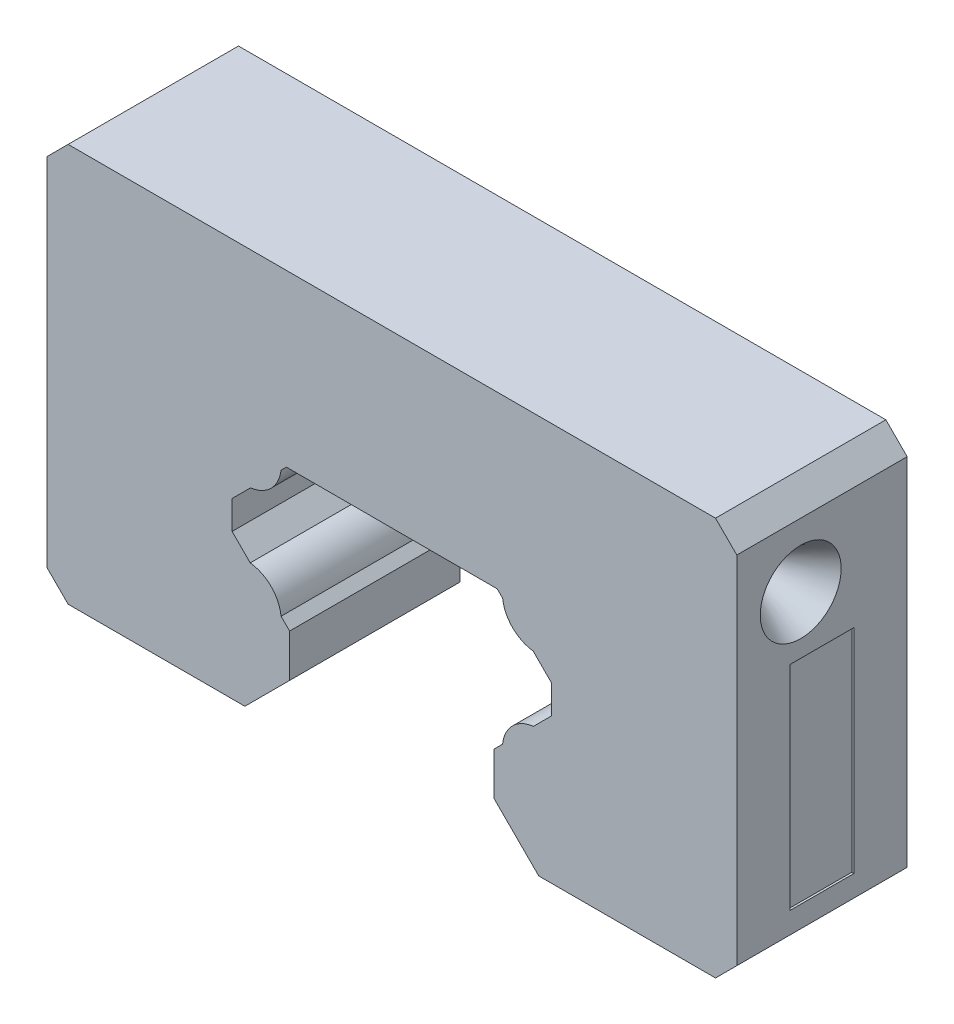
from build123d import *

# Parameters (mm, degrees)
EXTRUDE_1_DEPTH     = 8
SKETCH_1_R          = 1.9
CUT_EXTRUDE_1_DEPTH = 3
CUT_EXTRUDE_1_TAPER = 31
SKETCH_2_R          = 1.9
CUT_EXTRUDE_2_DEPTH = 3
CUT_EXTRUDE_2_TAPER = 31
SKETCH_3_W          = 3
SKETCH_3_H          = 10
CUT_EXTRUDE_5_DEPTH = 0.1
SKETCH_4_W          = 3
SKETCH_4_H          = 10
CUT_EXTRUDE_6_DEPTH = 0.1
EXTRUDE_2_DEPTH     = 0.1


with BuildPart() as part:
    # Model → Бобышка-Вытянуть1 (new body)
    with BuildSketch(Plane.XY):
        with BuildLine():
            Line((4.7998047, 2.0996344), (6.8994391, 0))
            Line((6.8994391, 0), (15.2, 0))
            Line((15.2, 0), (16.2, 1))
            Line((16.2, 1), (16.2, 17.7))
            Line((16.2, 17.7), (15.2, 18.7))
            Line((15.2, 18.7), (-15.2, 18.7))
            Line((-15.2, 18.7), (-16.2, 17.7))
            Line((-16.2, 17.7), (-16.2, 1))
            Line((-16.2, 1), (-15.2, 0))
            Line((-15.2, 0), (-6.8994391, 0))
            Line((-6.8994391, 0), (-4.7998047, 2.0996344))
            Line((-4.7998047, 2.0996344), (-4.7998047, 4.109149262))
            Line((-4.7998047, 4.109149262), (-5.20075838, 4.510103152))
            ThreePointArc((-5.20075838, 4.510103152), (-5.668922208, 5.489261508), (-6.648080611, 5.957425238))
            Line((-6.648080611, 5.957425238), (-7.5, 6.809345046))
            Line((-7.5, 6.809345046), (-7.5, 8.149454443))
            Line((-7.5, 8.149454443), (-6.634490912, 9.014965186))
            ThreePointArc((-6.634490912, 9.014965186), (-5.668922174, 9.481617126), (-5.202270193, 10.447185846))
            Line((-5.202270193, 10.447185846), (-4.949456226, 10.7))
            Line((-4.949456226, 10.7), (4.949456226, 10.7))
            Line((4.949456226, 10.7), (5.202270193, 10.447185846))
            ThreePointArc((5.202270193, 10.447185846), (5.668922174, 9.481617126), (6.634490912, 9.014965186))
            Line((6.634490912, 9.014965186), (7.5, 8.149454443))
            Line((7.5, 8.149454443), (7.5, 6.809345046))
            Line((7.5, 6.809345046), (6.648080611, 5.957425238))
            ThreePointArc((6.648080611, 5.957425238), (5.668922208, 5.489261508), (5.20075838, 4.510103152))
            Line((5.20075838, 4.510103152), (4.7998047, 4.109149262))
            Line((4.7998047, 4.109149262), (4.7998047, 2.0996344))
        make_face()
    extrude(amount=EXTRUDE_1_DEPTH)

    # Эскиз1 → Вырез-Вытянуть1 (cut)
    with BuildSketch(Plane.ZY.offset(16.2)):
        with Locations((5, 14.7)):
            Circle(SKETCH_1_R)
    extrude(amount=-CUT_EXTRUDE_1_DEPTH, taper=CUT_EXTRUDE_1_TAPER, mode=Mode.SUBTRACT)

    # Эскиз2 → Вырез-Вытянуть2 (cut)
    with BuildSketch(Plane(origin=(16.2, 0, 0), x_dir=(0, 0, -1), z_dir=(1, 0, 0))):
        with Locations((-5, 14.7)):
            Circle(SKETCH_2_R)
    extrude(amount=-CUT_EXTRUDE_2_DEPTH, taper=CUT_EXTRUDE_2_TAPER, mode=Mode.SUBTRACT)

    # Эскиз3 → Вырез-Вытянуть5 (cut)
    with BuildSketch(Plane.ZY.offset(16.2)):
        with Locations((4, 7)):
            Rectangle(SKETCH_3_W, SKETCH_3_H)
    extrude(amount=-CUT_EXTRUDE_5_DEPTH, mode=Mode.SUBTRACT)

    # Эскиз4 → Вырез-Вытянуть6 (cut)
    with BuildSketch(Plane(origin=(16.2, 0, 0), x_dir=(0, 0, -1), z_dir=(1, 0, 0))):
        with Locations((-4, 7)):
            Rectangle(SKETCH_4_W, SKETCH_4_H)
    extrude(amount=-CUT_EXTRUDE_6_DEPTH, mode=Mode.SUBTRACT)

    # Эскиз6 → Бобышка-Вытянуть2 (add)
    with BuildSketch(Plane.ZY.offset(16.1)):
        Polygon((3.03007211, 3.44508547), (3.03007211, 3.635042735), (3.898448178, 3.635042735), (3.898448178, 4.720512821), (3.03007211, 4.720512821), (3.03007211, 4.910470085), (5.146738777, 4.910470085), (5.146738777, 4.720512821), (4.115542195, 4.720512821), (4.115542195, 3.635042735), (5.146738777, 3.635042735), (5.146738777, 3.44508547), align=None)
        with BuildLine():
            Line((3.418466875, 7.407051282), (3.5456704, 7.240838675))
            add(Edge.make_bspline(
                [(3.5456704, 7.240838675), (3.531539739, 7.228981659), (3.503468928, 7.205427486), (3.464048076, 7.167535373), (3.427128407, 7.128036745), (3.392472706, 7.086986558), (3.361473859, 7.043434815), (3.331717649, 6.999040962), (3.305665063, 6.952191972), (3.27383857, 6.88773774), (3.241351764, 6.803091843), (3.213410305, 6.696904819), (3.195791064, 6.5859033), (3.193869837, 6.510191456), (3.192892623, 6.471681357)],
                knots=[0, 0, 0, 0, 5.5327e-05, 0.000109907, 0.000163905, 0.000217489, 0.000270921, 0.000324195, 0.000377734, 0.000431589, 0.000539781, 0.000649006, 0.000760546, 0.000876009, 0.000876009, 0.000876009, 0.000876009], degree=3))
            add(Edge.make_bspline(
                [(3.192892623, 6.471681357), (3.193136924, 6.450464314), (3.193623259, 6.408227142), (3.200039254, 6.345544494), (3.209056985, 6.284032315), (3.222437538, 6.223730619), (3.239354312, 6.164716163), (3.259568731, 6.106603141), (3.284578555, 6.050232912), (3.312221197, 5.994825728), (3.343443407, 5.941740068), (3.377499946, 5.891512036), (3.414007532, 5.844321884), (3.453110993, 5.800143045), (3.494604828, 5.758890728), (3.538953905, 5.721084035), (3.585684118, 5.686217839), (3.634834276, 5.654490849), (3.685946619, 5.62592919), (3.739312968, 5.601913277), (3.794019585, 5.58093794), (3.850454299, 5.564079212), (3.908242017, 5.550838897), (3.967622137, 5.541685152), (4.028482077, 5.535343514), (4.069732399, 5.534859408), (4.090525502, 5.534615385)],
                knots=[0, 0, 0, 0, 6.3624e-05, 0.000126658, 0.000188844, 0.000250057, 0.000311794, 0.000372946, 0.000434469, 0.000496666, 0.000558624, 0.000619072, 0.00067861, 0.000737485, 0.000795951, 0.000853991, 0.000912166, 0.000970736, 0.001029382, 0.001087634, 0.001146144, 0.001205033, 0.001264178, 0.001323849, 0.001385195, 0.001447548, 0.001447548, 0.001447548, 0.001447548], degree=3))
            add(Edge.make_bspline(
                [(4.090525502, 5.534615385), (4.121809936, 5.535380274), (4.183232773, 5.536882033), (4.273213471, 5.550190625), (4.35949779, 5.57057678), (4.441501507, 5.600629843), (4.519908222, 5.638426338), (4.593767093, 5.685585942), (4.664160174, 5.740411748), (4.729382586, 5.803466198), (4.788959092, 5.872656307), (4.841422762, 5.946889083), (4.885155989, 6.025982566), (4.921548125, 6.109062684), (4.949522427, 6.196768963), (4.96921597, 6.288943626), (4.982062431, 6.385386215), (4.983292328, 6.451286756), (4.983918264, 6.484825721)],
                knots=[0, 0, 0, 0, 9.3802e-05, 0.000184169, 0.000272303, 0.000359354, 0.000445638, 0.000532922, 0.000621728, 0.000712892, 0.000804597, 0.000895294, 0.000985074, 0.00107527, 0.00116699, 0.00126072, 0.001357753, 0.001458316, 0.001458316, 0.001458316, 0.001458316], degree=3))
            add(Edge.make_bspline(
                [(4.983918264, 6.484825721), (4.982896954, 6.5217783), (4.980886772, 6.594509814), (4.963857131, 6.701170478), (4.936244962, 6.803275917), (4.897601933, 6.900831624), (4.847367211, 6.993562577), (4.786468971, 7.08161389), (4.714327931, 7.165059888), (4.659244325, 7.215237758), (4.631140486, 7.240838675)],
                knots=[0, 0, 0, 0, 0.000110804, 0.000218089, 0.000323109, 0.000427593, 0.000532126, 0.000638803, 0.000748216, 0.000862188, 0.000862188, 0.000862188, 0.000862188], degree=3))
            Line((4.631140486, 7.240838675), (4.757071976, 7.407051282))
            add(Edge.make_bspline(
                [(4.757071976, 7.407051282), (4.774330348, 7.393674623), (4.808764424, 7.366985378), (4.857318554, 7.323777247), (4.902947426, 7.27822642), (4.945423169, 7.23021581), (4.984921597, 7.179660797), (5.021464167, 7.126566019), (5.054856947, 7.070976799), (5.085529855, 7.013334674), (5.112536311, 6.95350682), (5.136467976, 6.892019928), (5.156280751, 6.828496996), (5.173040135, 6.763472746), (5.18499033, 6.696359917), (5.19450653, 6.627938646), (5.200152244, 6.557568533), (5.20072303, 6.510135067), (5.201012281, 6.486097756)],
                knots=[0, 0, 0, 0, 6.5492e-05, 0.00013067, 0.000194831, 0.000258812, 0.000322851, 0.000387185, 0.000452049, 0.000517297, 0.000582953, 0.000648861, 0.000715107, 0.000782466, 0.000850162, 0.000919482, 0.000989661, 0.001061763, 0.001061763, 0.001061763, 0.001061763], degree=3))
            add(Edge.make_bspline(
                [(5.201012281, 6.486097756), (5.200853838, 6.463332301), (5.200540536, 6.418316431), (5.195465273, 6.351853853), (5.188540908, 6.28715063), (5.178114734, 6.224391689), (5.165811252, 6.163234552), (5.149318635, 6.104233627), (5.130843663, 6.046808333), (5.109129694, 5.991189384), (5.084627051, 5.937329471), (5.05693406, 5.885402309), (5.026283599, 5.835431781), (4.993351283, 5.786926597), (4.957079296, 5.740603297), (4.917971379, 5.696060451), (4.876159344, 5.653048286), (4.846009028, 5.626437139), (4.830850021, 5.613057559)],
                knots=[0, 0, 0, 0, 6.8278e-05, 0.000135011, 0.000199862, 0.000263436, 0.000325805, 0.000386905, 0.00044711, 0.000506717, 0.000565916, 0.000624529, 0.000683141, 0.00074171, 0.000800319, 0.000859512, 0.00091948, 0.000980118, 0.000980118, 0.000980118, 0.000980118], degree=3))
            add(Edge.make_bspline(
                [(4.830850021, 5.613057559), (4.804517426, 5.591628829), (4.752170145, 5.549030077), (4.667338526, 5.494504917), (4.578845997, 5.447987288), (4.486179995, 5.409956221), (4.389304495, 5.380743924), (4.288375342, 5.36020578), (4.183594299, 5.346952547), (4.112332103, 5.345431352), (4.076109102, 5.34465812)],
                knots=[0, 0, 0, 0, 0.000101785, 0.000202341, 0.000301912, 0.00040136, 0.000502365, 0.000604981, 0.000710061, 0.00081869, 0.00081869, 0.00081869, 0.00081869], degree=3))
            add(Edge.make_bspline(
                [(4.076109102, 5.34465812), (4.038036042, 5.345598641), (3.963129674, 5.347449059), (3.853199711, 5.363170326), (3.74787958, 5.388460741), (3.647365887, 5.424381717), (3.551129955, 5.469923524), (3.459906941, 5.526182476), (3.373113448, 5.592504986), (3.292066432, 5.668370896), (3.217959299, 5.75156638), (3.152762214, 5.840659186), (3.098504478, 5.935474935), (3.053149656, 6.034969065), (3.018288481, 6.139886596), (2.993884411, 6.250003681), (2.978694536, 6.365113406), (2.976774291, 6.443649254), (2.975798606, 6.483553686)],
                knots=[0, 0, 0, 0, 0.000114173, 0.000224627, 0.000332404, 0.00043862, 0.000544262, 0.000651234, 0.000759531, 0.000871432, 0.000983759, 0.001093336, 0.001201992, 0.001310916, 0.001420865, 0.001532991, 0.001648852, 0.001768532, 0.001768532, 0.001768532, 0.001768532], degree=3))
            add(Edge.make_bspline(
                [(2.975798606, 6.483553686), (2.976090438, 6.507873787), (2.976668091, 6.556012977), (2.982292415, 6.627226452), (2.991687967, 6.696553513), (3.004408927, 6.764067071), (3.020428409, 6.829962314), (3.040393815, 6.894115962), (3.064164034, 6.956370918), (3.091308523, 7.016706958), (3.121832344, 7.074716781), (3.155375462, 7.13036397), (3.191768392, 7.183426672), (3.231383714, 7.233629093), (3.273892824, 7.281032652), (3.318797787, 7.326340539), (3.367250899, 7.368233884), (3.401363632, 7.394088463), (3.418466875, 7.407051282)],
                knots=[0, 0, 0, 0, 7.295e-05, 0.000144397, 0.000214137, 0.000282745, 0.000350413, 0.000417468, 0.000484168, 0.00055021, 0.000615833, 0.000680697, 0.000745031, 0.000808736, 0.0008724, 0.000935962, 0.000999983, 0.001064356, 0.001064356, 0.001064356, 0.001064356], degree=3))
        make_face()
        Polygon((3.03007211, 8.10115852), (3.03007211, 8.492521368), (5.146738777, 8.492521368), (5.146738777, 8.302564103), (3.247166127, 8.302564103), (3.247166127, 7.976923077), align=None)
        with BuildLine():
            Line((3.03007211, 10.609188034), (3.247166127, 10.609188034))
            Line((3.247166127, 10.609188034), (3.247166127, 9.889216079))
            Line((3.247166127, 9.889216079), (3.803893558, 9.775156918))
            add(Edge.make_bspline(
                [(3.803893558, 9.775156918), (3.797706679, 9.797566899), (3.78572058, 9.840982693), (3.772412328, 9.90506318), (3.764389893, 9.965897513), (3.763294482, 10.00537357), (3.762764418, 10.024475828)],
                knots=[0, 0, 0, 0, 6.973e-05, 0.000135091, 0.000196204, 0.000253502, 0.000253502, 0.000253502, 0.000253502], degree=3))
            add(Edge.make_bspline(
                [(3.762764418, 10.024475828), (3.763259112, 10.048116524), (3.764231805, 10.094600038), (3.774126413, 10.162505308), (3.788457948, 10.227654697), (3.810538389, 10.289086279), (3.837502547, 10.347771965), (3.871464492, 10.402703899), (3.911114979, 10.454653052), (3.956249801, 10.503260378), (4.006439366, 10.547149763), (4.06062635, 10.585288191), (4.117628301, 10.618575965), (4.178781229, 10.644537441), (4.242931768, 10.665724538), (4.310820433, 10.679695362), (4.381844523, 10.689027268), (4.430410232, 10.690067725), (4.455175609, 10.690598291)],
                knots=[0, 0, 0, 0, 7.0872e-05, 0.000139352, 0.000205489, 0.000270662, 0.000334778, 0.000398917, 0.000463963, 0.000530566, 0.000597578, 0.000663578, 0.000729108, 0.000795195, 0.000862508, 0.00093145, 0.001002817, 0.001077079, 0.001077079, 0.001077079, 0.001077079], degree=3))
            add(Edge.make_bspline(
                [(4.455175609, 10.690598291), (4.472424653, 10.690195716), (4.506689636, 10.689396008), (4.557578424, 10.685338174), (4.607382449, 10.677495384), (4.656010406, 10.667093408), (4.703507837, 10.653207285), (4.750140679, 10.636964939), (4.795398305, 10.616776778), (4.8394806, 10.594395947), (4.881883057, 10.569613394), (4.921589001, 10.541745964), (4.959504529, 10.512790099), (4.994503608, 10.48115047), (5.026721994, 10.447186804), (5.056318966, 10.411088076), (5.083825702, 10.373181709), (5.108117527, 10.332870681), (5.130471414, 10.291056071), (5.148809908, 10.247133257), (5.16520533, 10.202102271), (5.178273947, 10.155314939), (5.188514111, 10.106877253), (5.195469236, 10.056709365), (5.200534986, 10.005074389), (5.200852098, 9.970073786), (5.201012281, 9.95239383)],
                knots=[0, 0, 0, 0, 5.1757e-05, 0.000102815, 0.000153008, 0.000202908, 0.00025189, 0.000301376, 0.00035093, 0.000400423, 0.000449654, 0.000498112, 0.000545862, 0.000592695, 0.000639483, 0.000686172, 0.000732653, 0.000779848, 0.000827264, 0.000874755, 0.000922501, 0.000970959, 0.001020356, 0.001070906, 0.001122845, 0.001175862, 0.001175862, 0.001175862, 0.001175862], degree=3))
            add(Edge.make_bspline(
                [(5.201012281, 9.95239383), (5.200593365, 9.931303792), (5.199769197, 9.889811633), (5.191186415, 9.829012958), (5.178812605, 9.770551644), (5.160480135, 9.714678248), (5.13647507, 9.661625795), (5.107953422, 9.610634586), (5.073998837, 9.562336633), (5.034921885, 9.517062136), (4.991984548, 9.475444837), (4.945835323, 9.437705964), (4.896415435, 9.404526527), (4.843885583, 9.375786168), (4.788338942, 9.351302001), (4.72960436, 9.332059441), (4.667978651, 9.316530717), (4.625552545, 9.309960856), (4.604003734, 9.306623932)],
                knots=[0, 0, 0, 0, 6.3229e-05, 0.000124395, 0.000183862, 0.000242323, 0.0003004, 0.000358305, 0.000417357, 0.000477191, 0.000537462, 0.000596532, 0.000655803, 0.000715767, 0.000775954, 0.000837633, 0.000900981, 0.000966367, 0.000966367, 0.000966367, 0.000966367], degree=3))
            Line((4.604003734, 9.306623932), (4.604003734, 9.496581197))
            add(Edge.make_bspline(
                [(4.604003734, 9.496581197), (4.624190642, 9.50125221), (4.662991001, 9.510230156), (4.717471036, 9.529987783), (4.766036549, 9.553910329), (4.808984478, 9.5830199), (4.847100975, 9.61676162), (4.880708206, 9.655984626), (4.911064711, 9.699708356), (4.936411797, 9.748320556), (4.957763298, 9.799706004), (4.973000431, 9.853180925), (4.982223795, 9.907975712), (4.983351315, 9.944867772), (4.983918264, 9.963418136)],
                knots=[0, 0, 0, 0, 6.2114e-05, 0.000119387, 0.00017343, 0.000224117, 0.000274576, 0.000325673, 0.000378716, 0.000433913, 0.000489818, 0.000545382, 0.000600381, 0.000656005, 0.000656005, 0.000656005, 0.000656005], degree=3))
            add(Edge.make_bspline(
                [(4.983918264, 9.963418136), (4.983417735, 9.981534325), (4.982432191, 10.017205249), (4.974969121, 10.069727513), (4.963173223, 10.120287577), (4.946647846, 10.168975189), (4.92478574, 10.21555111), (4.897929403, 10.259949485), (4.866748877, 10.302802809), (4.831110673, 10.342983246), (4.791815046, 10.379774687), (4.749798923, 10.412284849), (4.704975575, 10.439364087), (4.658122843, 10.462184274), (4.608726742, 10.479512688), (4.557018894, 10.491874618), (4.502871548, 10.49913361), (4.465939156, 10.50013218), (4.447119386, 10.500641026)],
                knots=[0, 0, 0, 0, 5.4333e-05, 0.000106982, 0.000158818, 0.000209905, 0.000260931, 0.000312852, 0.000365349, 0.000419717, 0.000473714, 0.000526634, 0.000578774, 0.000630547, 0.000682714, 0.000735472, 0.000789802, 0.000846253, 0.000846253, 0.000846253, 0.000846253], degree=3))
            add(Edge.make_bspline(
                [(4.447119386, 10.500641026), (4.430138233, 10.500254902), (4.397040212, 10.499502307), (4.348447199, 10.492987144), (4.302395316, 10.482103667), (4.258684185, 10.466607806), (4.217453558, 10.447268477), (4.178794299, 10.422987362), (4.142342908, 10.394798374), (4.109037433, 10.361888368), (4.078249623, 10.326089095), (4.052098997, 10.286481046), (4.029860018, 10.244121608), (4.011639105, 10.198932284), (3.997124753, 10.15085741), (3.987093686, 10.099871093), (3.981091247, 10.045961713), (3.980276986, 10.009085967), (3.979858435, 9.990130876)],
                knots=[0, 0, 0, 0, 5.0926e-05, 9.9259e-05, 0.000146773, 0.000192637, 0.000238157, 0.000283102, 0.000329327, 0.000376103, 0.000423336, 0.000470729, 0.000518144, 0.000566647, 0.000616682, 0.000668571, 0.000722325, 0.000779182, 0.000779182, 0.000779182, 0.000779182], degree=3))
            add(Edge.make_bspline(
                [(3.979858435, 9.990130876), (3.980209554, 9.973724333), (3.980934527, 9.939848985), (3.986272456, 9.887886133), (3.994883838, 9.833281138), (4.006728855, 9.776243324), (4.022229554, 9.716601398), (4.040804513, 9.654481222), (4.063012579, 9.589752185), (4.079783966, 9.546138133), (4.088405443, 9.523717949)],
                knots=[0, 0, 0, 0, 4.9215e-05, 0.000101616, 0.000156548, 0.000215008, 0.0002763, 0.000341362, 0.000409479, 0.000481538, 0.000481538, 0.000481538, 0.000481538], degree=3))
            Line((4.088405443, 9.523717949), (3.03007211, 9.740811966))
            Line((3.03007211, 9.740811966), (3.03007211, 10.609188034))
        make_face()
    extrude(amount=EXTRUDE_2_DEPTH)


solid = part.part
